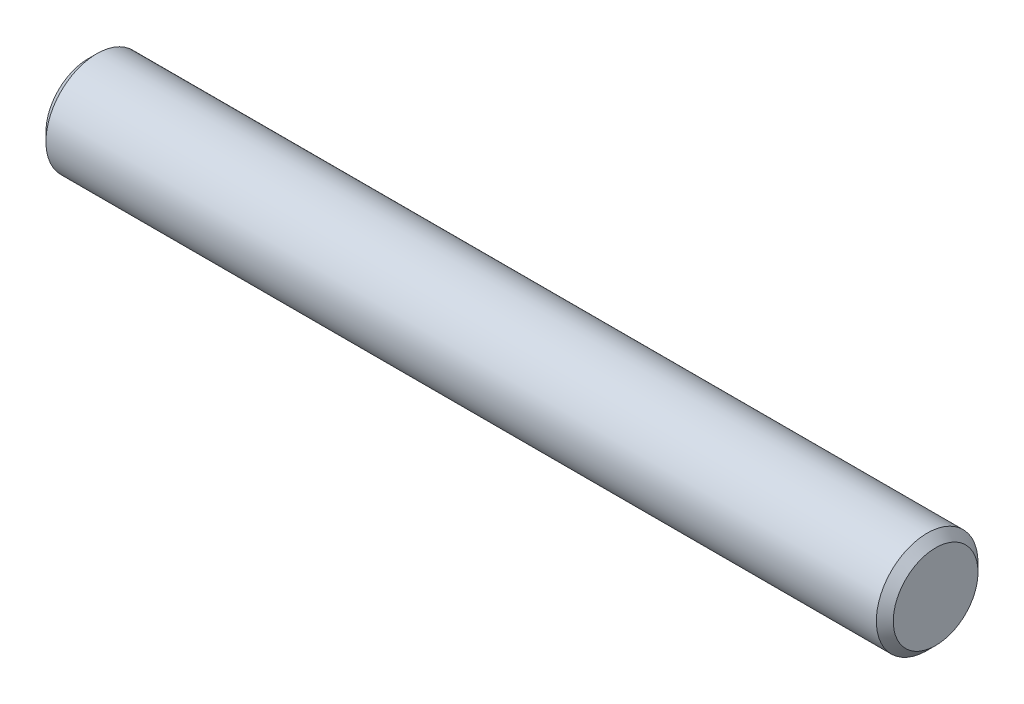
from build123d import *

# Parameters (mm, degrees)
SKETCH1_R      = 3
EXTRUDE1_DEPTH = 50
CHAMFER1_SIZE  = 0.5


with BuildPart() as part:
    # Sketch1 → Extrude1 (new body)
    with BuildSketch(Plane(origin=(0, 0, 0), x_dir=(0, 0, -1), z_dir=(1, 0, 0))):
        Circle(SKETCH1_R)
    extrude(amount=EXTRUDE1_DEPTH)

    # Chamfer1
    chamfer1_edges = [part.edges().sort_by_distance(p)[0] for p in [
        (0, 0, 3),
        (50, 0, 3),
    ]]
    chamfer(chamfer1_edges, length=CHAMFER1_SIZE)


solid = part.part
